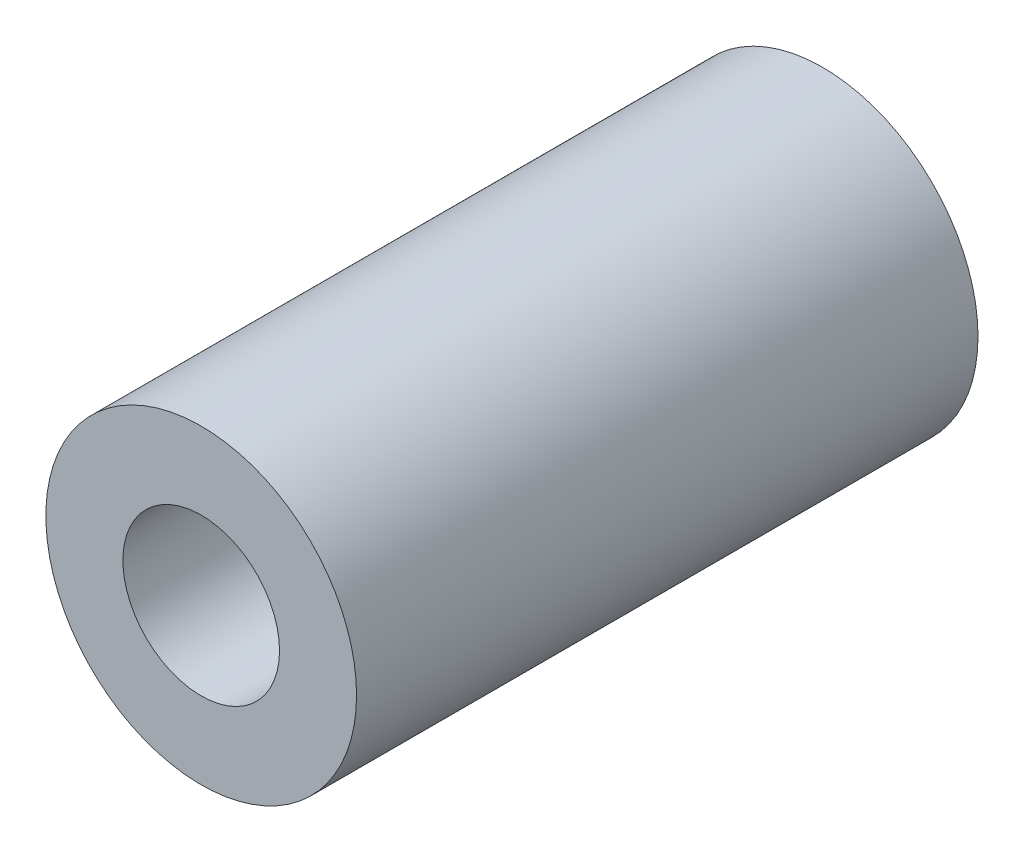
from build123d import *

# Parameters (mm, degrees)
SKETCH1_R           = 6.35
SKETCH1_R_2         = 3.2004
EXTRUDE1_DEPTH      = 12.7
EXTRUDE1_DEPTH_BACK = 12.7


with BuildPart() as part:
    # Sketch1 → Extrude1 (new body, two sides)
    with BuildSketch(Plane.XY) as extrude1_sk:
        Circle(SKETCH1_R)
        Circle(SKETCH1_R_2, mode=Mode.SUBTRACT)
    extrude(amount=EXTRUDE1_DEPTH)
    extrude(extrude1_sk.sketch, amount=-EXTRUDE1_DEPTH_BACK)


solid = part.part
